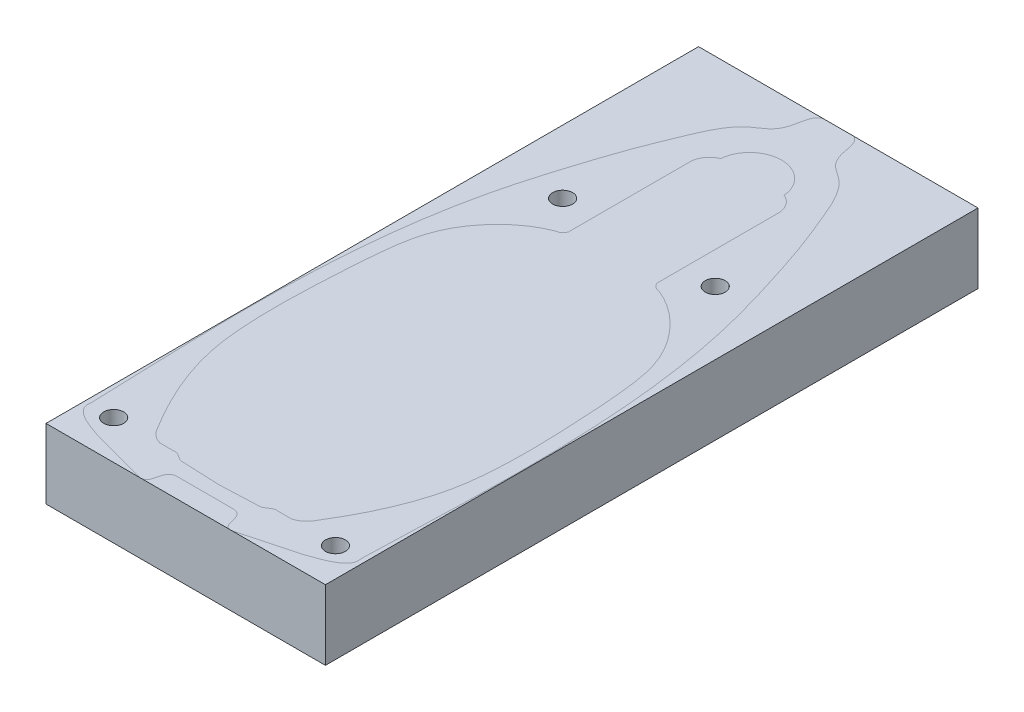
from build123d import *

# Parameters (mm, degrees)
SKETCH1_R           = 3.624738262
BOSS_EXTRUDE1_DEPTH = 25.4
SKETCH5_R           = 2.1
CUT_EXTRUDE1_DEPTH  = 6.35


with BuildPart() as part:
    # Sketch1 → Boss-Extrude1 (new body)
    with BuildSketch(Plane(origin=(0, 0, 0), x_dir=(1, 0, 0), z_dir=(0, 1, 0))):
        with BuildLine():
            Line((4.445513057, 217.442534033), (-4.445513057, 217.442534033))
            Line((-4.445513057, 217.442534033), (-5.102919532, 217.442534033))
            add(Edge.make_bspline(
                [(-5.102919532, 217.442534033), (-6.772186373, 217.270668093), (-8.307034074, 214.419403759), (-8.818468152, 209.809743179), (-10.450311171, 205.542036855), (-13.988349159, 202.878315551), (-17.135052097, 200.878659029), (-21.922509673, 195.198487494), (-25.105344828, 187.023597167), (-30.549633993, 174.097860197), (-35.960133295, 157.773461946), (-44.738307888, 128.665983431), (-52.530859765, 73.643219076), (-50.064387697, 26.1166546), (-49.077139095, -5.292317253)],
                knots=[0.002425274, 0.002425274, 0.002425274, 0.002425274, 0.022096851, 0.039559354, 0.063258598, 0.077264421, 0.095563037, 0.110967211, 0.171488249, 0.206517367, 0.29130997, 0.391743327, 0.59645674, 1, 1, 1, 1], degree=3))
            add(Edge.make_bspline(
                [(-49.077139095, -5.292317253), (-50.568888317, -10.940069386), (-38.832871978, -13.504300857), (-37.41909493, -14.341890116)],
                knots=[0, 0, 0, 0, 1, 1, 1, 1], degree=3))
            add(Edge.make_bspline(
                [(-37.41909493, -14.341890116), (-18.385240054, -19.414944059)],
                knots=[0, 0, 1, 1], degree=1))
            add(Edge.make_bspline(
                [(-18.385240054, -19.414944059), (-17.545507284, -19.711304849), (-16.873048404, -19.841855249), (-16.3294738, -19.841855411)],
                knots=[0, 0, 0, 0, 0.124003814, 0.124003814, 0.124003814, 0.124003814], degree=3))
            add(Edge.make_bspline(
                [(-16.3294738, -19.841855411), (-12.489517066, -19.841856555), (-15.081386178, -13.326893789), (-10.571420329, -12.727383648)],
                knots=[0.124003814, 0.124003814, 0.124003814, 0.124003814, 1, 1, 1, 1], degree=3))
            Line((-10.571420329, -12.727383648), (10.571420329, -12.727383648))
            add(Edge.make_bspline(
                [(16.329472805, -19.841855411), (12.489517514, -19.84185543), (15.081385788, -13.326893737), (10.571420329, -12.727383648)],
                knots=[0.12400389, 0.12400389, 0.12400389, 0.12400389, 1, 1, 1, 1], degree=3))
            add(Edge.make_bspline(
                [(18.385240054, -19.414944059), (17.545506772, -19.71130503), (16.873047584, -19.841855409), (16.329472805, -19.841855411)],
                knots=[0, 0, 0, 0, 0.12400389, 0.12400389, 0.12400389, 0.12400389], degree=3))
            add(Edge.make_bspline(
                [(37.41909493, -14.341890116), (18.385240054, -19.414944059)],
                knots=[0, 0, 1, 1], degree=1))
            add(Edge.make_bspline(
                [(49.077139095, -5.292317253), (50.568888317, -10.940069386), (38.832871978, -13.504300857), (37.41909493, -14.341890116)],
                knots=[0, 0, 0, 0, 1, 1, 1, 1], degree=3))
            add(Edge.make_bspline(
                [(5.102919532, 217.442534033), (6.772186373, 217.270668093), (8.307034074, 214.419403759), (8.818468152, 209.809743179), (10.450311171, 205.542036855), (13.988349159, 202.878315551), (17.135052097, 200.878659029), (21.922509673, 195.198487494), (25.105344828, 187.023597167), (30.549633993, 174.097860197), (35.960133295, 157.773461946), (44.738307888, 128.665983431), (52.530859765, 73.643219076), (50.064387697, 26.1166546), (49.077139095, -5.292317253)],
                knots=[0.002425274, 0.002425274, 0.002425274, 0.002425274, 0.022096851, 0.039559354, 0.063258598, 0.077264421, 0.095563037, 0.110967211, 0.171488249, 0.206517367, 0.29130997, 0.391743327, 0.59645674, 1, 1, 1, 1], degree=3))
            Line((5.102919532, 217.442534033), (4.445513057, 217.442534033))
        make_face()
        with Locations((-40.32062291, -5.716007511)):
            Circle(SKETCH1_R, mode=Mode.SUBTRACT)
        with Locations((40.32062291, -5.716007511)):
            Circle(SKETCH1_R, mode=Mode.SUBTRACT)
        with BuildLine():
            Line((-16.104538235, 135.534945765), (-16.104538235, 179.489872376))
            ThreePointArc((-16.104538235, 179.489872376), (-14.856838211, 183.535157802), (-11.547275104, 186.174832321))
            ThreePointArc((-11.547275104, 186.174832321), (0, 196.808755074), (11.547275104, 186.174832321))
            ThreePointArc((11.547275104, 186.174832321), (14.856838211, 183.535157802), (16.104538235, 179.489872376))
            Line((16.104538235, 179.489872376), (16.104538235, 135.534945765))
            ThreePointArc((16.104538235, 135.534945765), (17.083827395, 134.03150708), (18.744661517, 133.352562929))
            add(Edge.make_bspline(
                [(18.744661517, 133.352562929), (24.072442652, 131.2924301), (32.602974887, 124.998790744), (41.637553202, 111.373856913), (43.965647761, 96.124513555), (45.050077329, 79.52972727), (45.881637514, 62.808624531), (45.602911581, 47.686022443), (43.216376699, 25.657328118), (35.94711566, 10.098547862), (28.989754302, -1.112627042)],
                knots=[0, 0, 0, 0, 0.114751729, 0.21197508, 0.323247979, 0.422594947, 0.550935393, 0.662789023, 0.729556884, 1, 1, 1, 1], degree=3))
            add(Edge.make_bspline(
                [(28.989754302, -1.112627042), (27.974155949, -3.099869503), (26.103151689, -4.730794842), (23.929709743, -5.292317253)],
                knots=[0, 0, 0, 0, 1, 1, 1, 1], degree=3))
            Line((23.929709743, -5.292317253), (19.001271831, -5.292317253))
            add(Edge.make_bspline(
                [(19.001271831, -5.292317253), (16.993440786, -4.847564795), (16.076709154, -6.856231256), (14.305888181, -7.108132642)],
                knots=[0, 0, 0, 0, 1, 1, 1, 1], degree=3))
            Line((14.305888181, -7.108132642), (0, -7.713404439))
            Line((0, -7.713404439), (-14.305888181, -7.108132642))
            add(Edge.make_bspline(
                [(-19.001271831, -5.292317253), (-16.993440786, -4.847564795), (-16.076709154, -6.856231256), (-14.305888181, -7.108132642)],
                knots=[0, 0, 0, 0, 1, 1, 1, 1], degree=3))
            Line((-19.001271831, -5.292317253), (-23.929709743, -5.292317253))
            add(Edge.make_bspline(
                [(-28.989754302, -1.112627042), (-27.974155949, -3.099869503), (-26.103151689, -4.730794842), (-23.929709743, -5.292317253)],
                knots=[0, 0, 0, 0, 1, 1, 1, 1], degree=3))
            add(Edge.make_bspline(
                [(-18.744661517, 133.352562929), (-24.072442652, 131.2924301), (-32.602974887, 124.998790744), (-41.637553202, 111.373856913), (-43.965647761, 96.124513555), (-45.050077329, 79.52972727), (-45.881637514, 62.808624531), (-45.602911581, 47.686022443), (-43.216376699, 25.657328118), (-35.94711566, 10.098547862), (-28.989754302, -1.112627042)],
                knots=[0, 0, 0, 0, 0.114751729, 0.21197508, 0.323247979, 0.422594947, 0.550935393, 0.662789023, 0.729556884, 1, 1, 1, 1], degree=3))
            ThreePointArc((-18.744661517, 133.352562929), (-17.083827395, 134.03150708), (-16.104538235, 135.534945765))
        make_face(mode=Mode.SUBTRACT)
        with Locations((-27.744990659, 144.952451062)):
            Circle(SKETCH1_R, mode=Mode.SUBTRACT)
        with Locations((27.744990659, 144.952451062)):
            Circle(SKETCH1_R, mode=Mode.SUBTRACT)
        with BuildLine():
            add(Edge.make_bspline(
                [(4.445513057, 217.442534033), (4.678303612, 217.464565791), (4.897118606, 217.463723077), (5.102919532, 217.442534033)],
                knots=[0, 0, 0, 0, 0.002425274, 0.002425274, 0.002425274, 0.002425274], degree=3))
            Line((4.445513057, 217.442534033), (5.102919532, 217.442534033))
        make_face()
        with BuildLine():
            add(Edge.make_bspline(
                [(-5.102919532, 217.442534033), (-6.772186373, 217.270668093), (-8.307034074, 214.419403759), (-8.818468152, 209.809743179), (-10.450311171, 205.542036855), (-13.988349159, 202.878315551), (-17.135052097, 200.878659029), (-21.922509673, 195.198487494), (-25.105344828, 187.023597167), (-30.549633993, 174.097860197), (-35.960133295, 157.773461946), (-44.738307888, 128.665983431), (-52.530859765, 73.643219076), (-50.064387697, 26.1166546), (-49.077139095, -5.292317253)],
                knots=[0.002425274, 0.002425274, 0.002425274, 0.002425274, 0.022096851, 0.039559354, 0.063258598, 0.077264421, 0.095563037, 0.110967211, 0.171488249, 0.206517367, 0.29130997, 0.391743327, 0.59645674, 1, 1, 1, 1], degree=3))
            Line((-5.102919532, 217.442534033), (-50.8, 217.442534033))
            Line((-50.8, 217.442534033), (-50.8, -19.841855411))
            Line((-50.8, -19.841855411), (-16.3294738, -19.841855411))
            add(Edge.make_bspline(
                [(-18.385240054, -19.414944059), (-17.545507284, -19.711304849), (-16.873048404, -19.841855249), (-16.3294738, -19.841855411)],
                knots=[0, 0, 0, 0, 0.124003814, 0.124003814, 0.124003814, 0.124003814], degree=3))
            add(Edge.make_bspline(
                [(-37.41909493, -14.341890116), (-18.385240054, -19.414944059)],
                knots=[0, 0, 1, 1], degree=1))
            add(Edge.make_bspline(
                [(-49.077139095, -5.292317253), (-50.568888317, -10.940069386), (-38.832871978, -13.504300857), (-37.41909493, -14.341890116)],
                knots=[0, 0, 0, 0, 1, 1, 1, 1], degree=3))
        make_face()
        with BuildLine():
            Line((50.8, 217.442534033), (5.102919532, 217.442534033))
            add(Edge.make_bspline(
                [(5.102919532, 217.442534033), (6.772186373, 217.270668093), (8.307034074, 214.419403759), (8.818468152, 209.809743179), (10.450311171, 205.542036855), (13.988349159, 202.878315551), (17.135052097, 200.878659029), (21.922509673, 195.198487494), (25.105344828, 187.023597167), (30.549633993, 174.097860197), (35.960133295, 157.773461946), (44.738307888, 128.665983431), (52.530859765, 73.643219076), (50.064387697, 26.1166546), (49.077139095, -5.292317253)],
                knots=[0.002425274, 0.002425274, 0.002425274, 0.002425274, 0.022096851, 0.039559354, 0.063258598, 0.077264421, 0.095563037, 0.110967211, 0.171488249, 0.206517367, 0.29130997, 0.391743327, 0.59645674, 1, 1, 1, 1], degree=3))
            add(Edge.make_bspline(
                [(49.077139095, -5.292317253), (50.568888317, -10.940069386), (38.832871978, -13.504300857), (37.41909493, -14.341890116)],
                knots=[0, 0, 0, 0, 1, 1, 1, 1], degree=3))
            add(Edge.make_bspline(
                [(37.41909493, -14.341890116), (18.385240054, -19.414944059)],
                knots=[0, 0, 1, 1], degree=1))
            add(Edge.make_bspline(
                [(18.385240054, -19.414944059), (17.545506772, -19.71130503), (16.873047584, -19.841855409), (16.329472805, -19.841855411)],
                knots=[0, 0, 0, 0, 0.12400389, 0.12400389, 0.12400389, 0.12400389], degree=3))
            Line((16.329472805, -19.841855411), (50.8, -19.841855411))
            Line((50.8, -19.841855411), (50.8, 217.442534033))
        make_face()
        with BuildLine():
            add(Edge.make_bspline(
                [(-16.3294738, -19.841855411), (-12.489517066, -19.841856555), (-15.081386178, -13.326893789), (-10.571420329, -12.727383648)],
                knots=[0.124003814, 0.124003814, 0.124003814, 0.124003814, 1, 1, 1, 1], degree=3))
            Line((-16.3294738, -19.841855411), (16.329472805, -19.841855411))
            add(Edge.make_bspline(
                [(16.329472805, -19.841855411), (12.489517514, -19.84185543), (15.081385788, -13.326893737), (10.571420329, -12.727383648)],
                knots=[0.12400389, 0.12400389, 0.12400389, 0.12400389, 1, 1, 1, 1], degree=3))
            Line((10.571420329, -12.727383648), (-10.571420329, -12.727383648))
        make_face()
        with BuildLine():
            ThreePointArc((-11.547275104, 186.174832321), (-14.856838211, 183.535157802), (-16.104538235, 179.489872376))
            Line((-16.104538235, 179.489872376), (-16.104538235, 135.534945765))
            ThreePointArc((-16.104538235, 135.534945765), (-17.083827395, 134.03150708), (-18.744661517, 133.352562929))
            add(Edge.make_bspline(
                [(-18.744661517, 133.352562929), (-24.072442652, 131.2924301), (-32.602974887, 124.998790744), (-41.637553202, 111.373856913), (-43.965647761, 96.124513555), (-45.050077329, 79.52972727), (-45.881637514, 62.808624531), (-45.602911581, 47.686022443), (-43.216376699, 25.657328118), (-35.94711566, 10.098547862), (-28.989754302, -1.112627042)],
                knots=[0, 0, 0, 0, 0.114751729, 0.21197508, 0.323247979, 0.422594947, 0.550935393, 0.662789023, 0.729556884, 1, 1, 1, 1], degree=3))
            add(Edge.make_bspline(
                [(-28.989754302, -1.112627042), (-27.974155949, -3.099869503), (-26.103151689, -4.730794842), (-23.929709743, -5.292317253)],
                knots=[0, 0, 0, 0, 1, 1, 1, 1], degree=3))
            Line((-23.929709743, -5.292317253), (-19.001271831, -5.292317253))
            add(Edge.make_bspline(
                [(-19.001271831, -5.292317253), (-16.993440786, -4.847564795), (-16.076709154, -6.856231256), (-14.305888181, -7.108132642)],
                knots=[0, 0, 0, 0, 1, 1, 1, 1], degree=3))
            Line((-14.305888181, -7.108132642), (0, -7.713404439))
            Line((0, -7.713404439), (14.305888181, -7.108132642))
            add(Edge.make_bspline(
                [(19.001271831, -5.292317253), (16.993440786, -4.847564795), (16.076709154, -6.856231256), (14.305888181, -7.108132642)],
                knots=[0, 0, 0, 0, 1, 1, 1, 1], degree=3))
            Line((19.001271831, -5.292317253), (23.929709743, -5.292317253))
            add(Edge.make_bspline(
                [(28.989754302, -1.112627042), (27.974155949, -3.099869503), (26.103151689, -4.730794842), (23.929709743, -5.292317253)],
                knots=[0, 0, 0, 0, 1, 1, 1, 1], degree=3))
            add(Edge.make_bspline(
                [(18.744661517, 133.352562929), (24.072442652, 131.2924301), (32.602974887, 124.998790744), (41.637553202, 111.373856913), (43.965647761, 96.124513555), (45.050077329, 79.52972727), (45.881637514, 62.808624531), (45.602911581, 47.686022443), (43.216376699, 25.657328118), (35.94711566, 10.098547862), (28.989754302, -1.112627042)],
                knots=[0, 0, 0, 0, 0.114751729, 0.21197508, 0.323247979, 0.422594947, 0.550935393, 0.662789023, 0.729556884, 1, 1, 1, 1], degree=3))
            ThreePointArc((18.744661517, 133.352562929), (17.083827395, 134.03150708), (16.104538235, 135.534945765))
            Line((16.104538235, 135.534945765), (16.104538235, 179.489872376))
            ThreePointArc((16.104538235, 179.489872376), (14.856838211, 183.535157802), (11.547275104, 186.174832321))
            ThreePointArc((11.547275104, 186.174832321), (0, 196.808755074), (-11.547275104, 186.174832321))
        make_face()
    extrude(amount=-BOSS_EXTRUDE1_DEPTH)

    # Sketch5 → Cut-Extrude1 (cut)
    with BuildSketch(Plane.XZ.offset(25.4)):
        with Locations((-13, -204.742534033)):
            Circle(SKETCH5_R)
        with Locations((13, -204.742534033)):
            Circle(SKETCH5_R)
        with Locations((-13, -163.742534033)):
            Circle(SKETCH5_R)
        with Locations((13, -163.742534033)):
            Circle(SKETCH5_R)
        with Locations((-13, -33.858144589)):
            Circle(SKETCH5_R)
        with Locations((13, -33.858144589)):
            Circle(SKETCH5_R)
        with Locations((-13, 7.141855411)):
            Circle(SKETCH5_R)
        with Locations((13, 7.141855411)):
            Circle(SKETCH5_R)
    extrude(amount=-CUT_EXTRUDE1_DEPTH, mode=Mode.SUBTRACT)


solid = part.part
